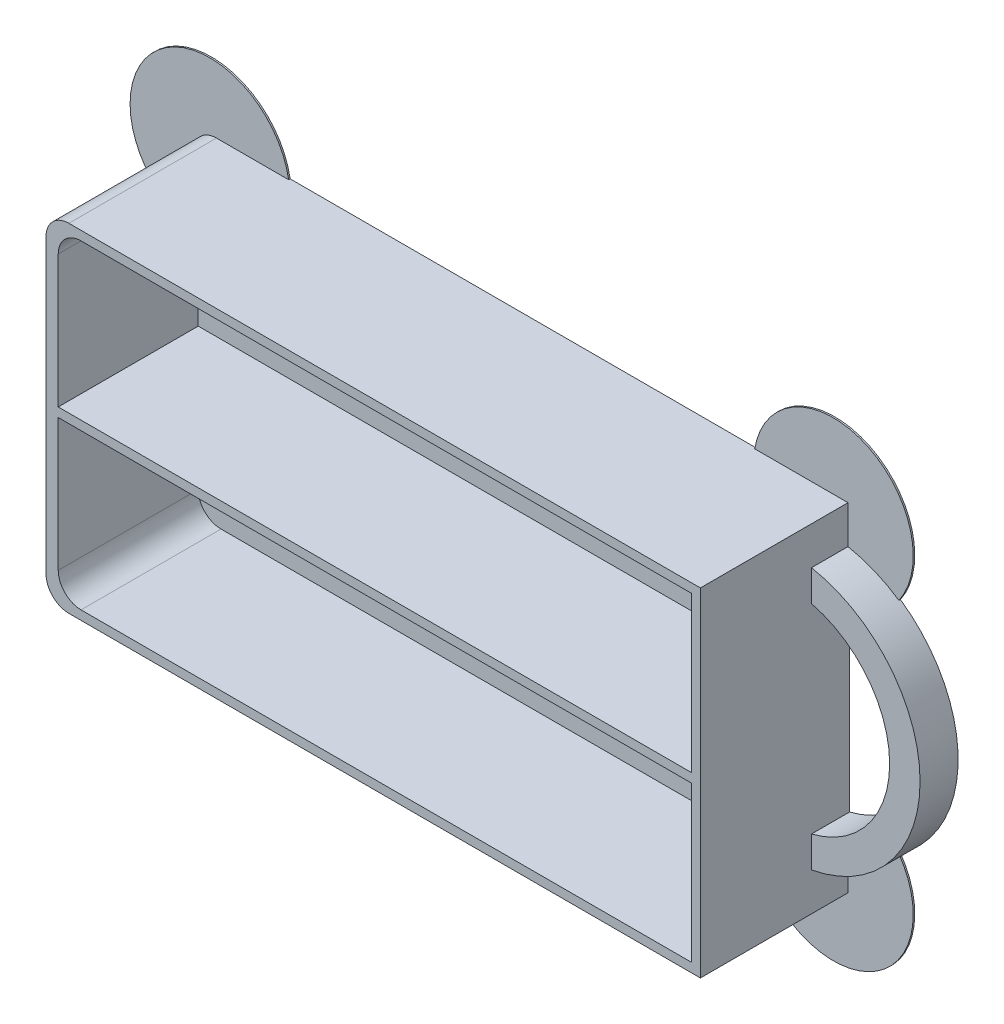
from build123d import *

# Parameters (mm, degrees)
SKETCH_1_W          = 86
SKETCH_1_H          = 44.4
EXTRUDE_1_DEPTH     = 19.6
EXTRUDE_2_DEPTH     = 5
SKETCH_3_W          = 83.2
SKETCH_3_H          = 20.402884615
SKETCH_3_H_2        = 20.397115385
CUT_EXTRUDE_1_DEPTH = 18.4
FILLET_1_R          = 3
EXTRUDE_3_DEPTH     = 0.2


with BuildPart() as part:
    # Эскиз1 → Бобышка-Вытянуть1 (new body)
    with BuildSketch(Plane.XY):
        Rectangle(SKETCH_1_W, SKETCH_1_H)
    extrude(amount=EXTRUDE_1_DEPTH)

    # Эскиз2 → Бобышка-Вытянуть2 (add)
    with BuildSketch(Plane.XY):
        with BuildLine():
            Line((43, 17.2), (43, 13.108775687))
            ThreePointArc((43, 13.108775687), (53.273546839, 0), (43, -13.108775687))
            Line((43, -13.108775687), (43, -17.2))
            ThreePointArc((43, -17.2), (57.273546839, 0), (43, 17.2))
        make_face()
    extrude(amount=EXTRUDE_2_DEPTH)

    # Эскиз3 → Вырез-Вытянуть1 (cut)
    with BuildSketch(Plane.XY.offset(19.6)):
        with Locations((0.2, 10.798557692)):
            Rectangle(SKETCH_3_W, SKETCH_3_H)
        with Locations((0.2, -10.801442308)):
            Rectangle(SKETCH_3_W, SKETCH_3_H_2)
    extrude(amount=-CUT_EXTRUDE_1_DEPTH, mode=Mode.SUBTRACT)

    # Скругление1
    fillet_1_edges = [part.edges().sort_by_distance(p)[0] for p in [
        (-41.4, 21, 10.4),
        (-41.4, -21, 10.4),
        (-43, -22.2, 9.8),
        (-43, 22.2, 9.8),
    ]]
    fillet(fillet_1_edges, radius=FILLET_1_R)

    # Эскиз4 → Бобышка-Вытянуть3 (add)
    with BuildSketch(Plane(origin=(0, 0, 0), x_dir=(-1, 0, 0), z_dir=(0, 0, -1))):
        with BuildLine():
            Line((-49.68910779, 14.419835333), (-30.736733343, 22.2))
            ThreePointArc((-30.736733343, 22.2), (-45.063461681, 30.125769311), (-49.68910779, 14.419835333))
        make_face()
        with BuildLine():
            Line((43, 10.144768059), (30.517095223, 22.2))
            ThreePointArc((30.517095223, 22.2), (48.148575221, 27.966485606), (43, 10.144768059))
        make_face()
        with BuildLine():
            Line((43, -10.144768059), (30.517095223, -22.2))
            ThreePointArc((30.517095223, -22.2), (48.148575221, -27.966485606), (43, -10.144768059))
        make_face()
        with BuildLine():
            Line((-49.68910779, -14.419835333), (-30.736733343, -22.2))
            ThreePointArc((-30.736733343, -22.2), (-45.063461681, -30.125769311), (-49.68910779, -14.419835333))
        make_face()
    extrude(amount=-EXTRUDE_3_DEPTH)


solid = part.part
